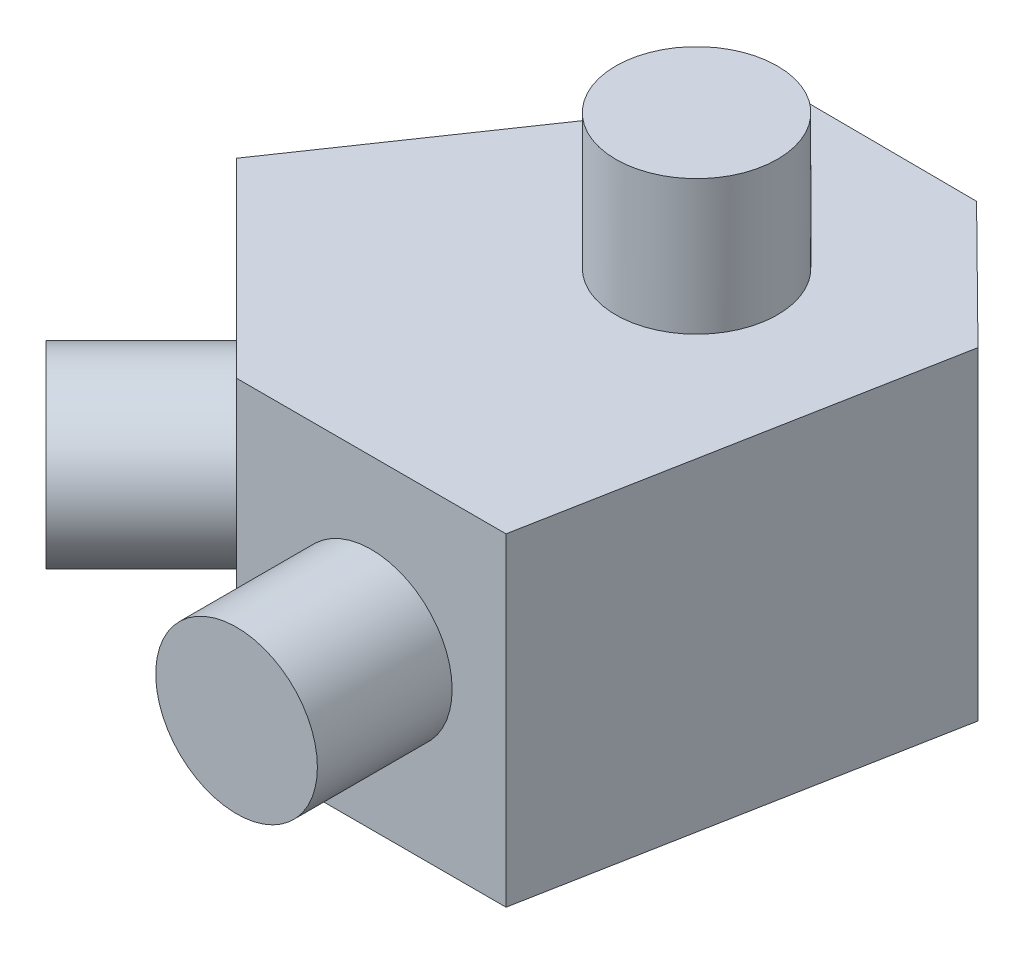
from build123d import *

# Parameters (mm, degrees)
BOSS_EXTRUDE1_DEPTH = 15.24
SKETCH2_R           = 3.81
BOSS_EXTRUDE2_DEPTH = 6.35
SKETCH5_R           = 3.81
BOSS_EXTRUDE3_DEPTH = 6.35


with BuildPart() as part:
    # Sketch1 → Boss-Extrude1 (new body)
    with BuildSketch(Plane(origin=(0, 0, 0), x_dir=(1, 0, 0), z_dir=(0, 1, 0))):
        Polygon((-8.980256121, 8.980256121), (0, 0), (12.7, 0), (16.220075072, 18.721954265), (10.214331376, 24.659577338), (1.769095743, 24.707745892), align=None)
    extrude(amount=BOSS_EXTRUDE1_DEPTH)

    # Sketch2 → Boss-Extrude2 (add)
    with BuildSketch(Plane.XY):
        with Locations((6.35, 7.62)):
            Circle(SKETCH2_R)
    boss_extrude2 = extrude(amount=BOSS_EXTRUDE2_DEPTH)

    # Mirror1: Boss-Extrude2 across plane
    add(boss_extrude2.mirror(Plane(origin=(0, 0, 0), x_dir=(-0.382683432, 0, 0.923879533), z_dir=(0.923879533, 0, 0.382683432))))

    # Sketch5 → Boss-Extrude3 (add)
    with BuildSketch(Plane(origin=(0, 15.24, 0), x_dir=(1, 0, 0), z_dir=(0, 1, 0))):
        with Locations((6.35, 15.330256121)):
            Circle(SKETCH5_R)
    extrude(amount=BOSS_EXTRUDE3_DEPTH)


solid = part.part
